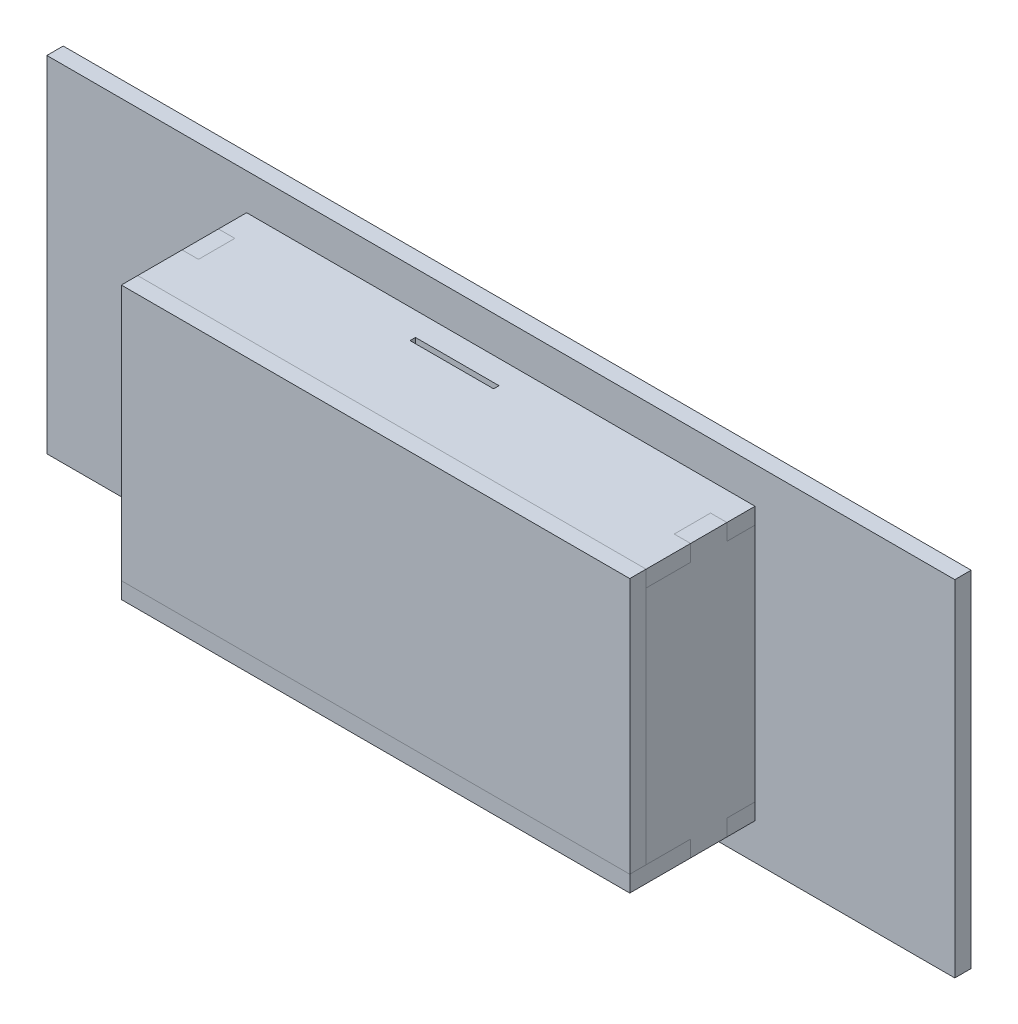
from build123d import *

# Parameters (mm, degrees)
ESQUISSE1_W             = 500
ESQUISSE1_H             = 190
ESQUISSE1_W_2           = 9
ESQUISSE1_H_2           = 37.5
ESQUISSE1_W_3           = 35
ESQUISSE1_H_3           = 9
BOSS_EXTRU_1_DEPTH      = 9
BOSS_EXTRU_2_START      = 9
ESQUISSE1_5_W           = 9
ESQUISSE1_5_H           = 9
ESQUISSE1_5_H_2         = 9.75
ESQUISSE1_5_H_3         = 37.5
BOSS_EXTRU_2_DEPTH      = 60
ESQUISSE1_6_W           = 9
ESQUISSE1_6_H           = 37.5
BOSS_EXTRU_3_DEPTH      = 9
ESQUISSE2_W             = 15.5
ESQUISSE2_H             = 9
ESQUISSE2_W_2           = 9
ENL_V_MAT_EXTRU_1_DEPTH = 408.291050724
BOSS_EXTRU_4_START      = 9
ESQUISSE1_7_W           = 35
ESQUISSE1_7_H           = 9
ESQUISSE1_7_W_2         = 8.5
ESQUISSE1_7_W_3         = 9
BOSS_EXTRU_4_DEPTH      = 60
ESQUISSE1_8_W           = 35
ESQUISSE1_8_H           = 9
BOSS_EXTRU_5_DEPTH      = 9
ESQUISSE3_W             = 9
ESQUISSE3_H             = 20
ENL_V_MAT_EXTRU_2_DEPTH = 311.098371489
BOSS_EXTRU_6_START      = 69
ESQUISSE1_9_W           = 9
ESQUISSE1_9_H           = 9
ESQUISSE1_9_W_2         = 8.5
ESQUISSE1_9_W_3         = 35
BOSS_EXTRU_6_DEPTH      = 9
BOSS_EXTRU_7_START      = 69
ESQUISSE1_10_W          = 262
ESQUISSE1_10_H          = 132
ESQUISSE1_10_W_2        = 9
ESQUISSE1_10_H_2        = 9.75
ESQUISSE1_10_H_3        = 37.5
ESQUISSE1_10_H_4        = 9
ESQUISSE1_10_W_3        = 8.5
ESQUISSE1_10_W_4        = 35
BOSS_EXTRU_7_DEPTH      = 9
ESQUISSE4_W             = 46
ESQUISSE4_H             = 3
ENL_V_MAT_EXTRU_3_DEPTH = 10


with BuildPart() as part:
    # Esquisse1 → Boss.-Extru.1 (new body)
    with BuildSketch(Plane.XY):
        Rectangle(ESQUISSE1_W, ESQUISSE1_H)
        with Locations((-135.5, 37.5)):
            Rectangle(ESQUISSE1_W_2, ESQUISSE1_H_2, mode=Mode.SUBTRACT)
        with Locations((-135.5, -37.5)):
            Rectangle(ESQUISSE1_W_2, ESQUISSE1_H_2, mode=Mode.SUBTRACT)
        with Locations((-105, -70.5)):
            Rectangle(ESQUISSE1_W_3, ESQUISSE1_H_3, mode=Mode.SUBTRACT)
        with Locations((-35, -70.5)):
            Rectangle(ESQUISSE1_W_3, ESQUISSE1_H_3, mode=Mode.SUBTRACT)
        with Locations((35, -70.5)):
            Rectangle(ESQUISSE1_W_3, ESQUISSE1_H_3, mode=Mode.SUBTRACT)
        with Locations((105, -70.5)):
            Rectangle(ESQUISSE1_W_3, ESQUISSE1_H_3, mode=Mode.SUBTRACT)
        with Locations((135.5, -37.5)):
            Rectangle(ESQUISSE1_W_2, ESQUISSE1_H_2, mode=Mode.SUBTRACT)
        with Locations((135.5, 37.5)):
            Rectangle(ESQUISSE1_W_2, ESQUISSE1_H_2, mode=Mode.SUBTRACT)
        with Locations((105, 70.5)):
            Rectangle(ESQUISSE1_W_3, ESQUISSE1_H_3, mode=Mode.SUBTRACT)
        with Locations((35, 70.5)):
            Rectangle(ESQUISSE1_W_3, ESQUISSE1_H_3, mode=Mode.SUBTRACT)
        with Locations((-35, 70.5)):
            Rectangle(ESQUISSE1_W_3, ESQUISSE1_H_3, mode=Mode.SUBTRACT)
        with Locations((-105, 70.5)):
            Rectangle(ESQUISSE1_W_3, ESQUISSE1_H_3, mode=Mode.SUBTRACT)
    extrude(amount=BOSS_EXTRU_1_DEPTH)


with BuildPart() as body_2:
    # Esquisse1_5 → Boss.-Extru.2 (new body)
    with BuildSketch(Plane.XY.offset(BOSS_EXTRU_2_START)):
        with Locations((-135.5, 70.5)):
            Rectangle(ESQUISSE1_5_W, ESQUISSE1_5_H)
        with Locations((-135.5, 61.125)):
            Rectangle(ESQUISSE1_5_W, ESQUISSE1_5_H_2)
        with Locations((-135.5, 37.5)):
            Rectangle(ESQUISSE1_5_W, ESQUISSE1_5_H_3)
        with Locations((-135.5, 0)):
            Rectangle(ESQUISSE1_5_W, ESQUISSE1_5_H_3)
        with Locations((-135.5, -37.5)):
            Rectangle(ESQUISSE1_5_W, ESQUISSE1_5_H_3)
        with Locations((-135.5, -61.125)):
            Rectangle(ESQUISSE1_5_W, ESQUISSE1_5_H_2)
        with Locations((-135.5, -70.5)):
            Rectangle(ESQUISSE1_5_W, ESQUISSE1_5_H)
    extrude(amount=BOSS_EXTRU_2_DEPTH)

    # Esquisse1_6 → Boss.-Extru.3 (add)
    with BuildSketch(Plane.XY):
        with Locations((-135.5, 37.5)):
            Rectangle(ESQUISSE1_6_W, ESQUISSE1_6_H)
        with Locations((-135.5, -37.5)):
            Rectangle(ESQUISSE1_6_W, ESQUISSE1_6_H)
    extrude(amount=BOSS_EXTRU_3_DEPTH)

    # Esquisse2 → Enlèv. mat.-Extru.1 (cut, through all)
    with BuildSketch(Plane.ZY.offset(140)):
        with Locations((16.75, 70.5)):
            Rectangle(ESQUISSE2_W, ESQUISSE2_H)
        with Locations((4.5, 70.5)):
            Rectangle(ESQUISSE2_W_2, ESQUISSE2_H)
        Polygon((44.5, 75), (44.5, 66), (60, 66), (69, 66), (69, 75), align=None)
        Polygon((69, -66), (60, -66), (44.5, -66), (44.5, -75), (69, -75), align=None)
        with Locations((16.75, -70.5)):
            Rectangle(ESQUISSE2_W, ESQUISSE2_H)
        with Locations((4.5, -70.5)):
            Rectangle(ESQUISSE2_W_2, ESQUISSE2_H)
    extrude(amount=-ENL_V_MAT_EXTRU_1_DEPTH, mode=Mode.SUBTRACT)


with BuildPart() as body_3:
    # Symétrie1: mirrored copy
    add(body_2.part.mirror(Plane(origin=(0, 0, 0), x_dir=(0, 0, 1), z_dir=(1, 0, 0))))


with BuildPart() as body_4:
    # Esquisse1_7 → Boss.-Extru.4 (new body)
    with BuildSketch(Plane.XY.offset(BOSS_EXTRU_4_START)):
        with Locations((-70, -70.5)):
            Rectangle(ESQUISSE1_7_W, ESQUISSE1_7_H)
        with Locations((-35, -70.5)):
            Rectangle(ESQUISSE1_7_W, ESQUISSE1_7_H)
        with Locations((0, -70.5)):
            Rectangle(ESQUISSE1_7_W, ESQUISSE1_7_H)
        with Locations((35, -70.5)):
            Rectangle(ESQUISSE1_7_W, ESQUISSE1_7_H)
        with Locations((70, -70.5)):
            Rectangle(ESQUISSE1_7_W, ESQUISSE1_7_H)
        with Locations((105, -70.5)):
            Rectangle(ESQUISSE1_7_W, ESQUISSE1_7_H)
        with Locations((126.75, -70.5)):
            Rectangle(ESQUISSE1_7_W_2, ESQUISSE1_7_H)
        with Locations((135.5, -70.5)):
            Rectangle(ESQUISSE1_7_W_3, ESQUISSE1_7_H)
        with Locations((-105, -70.5)):
            Rectangle(ESQUISSE1_7_W, ESQUISSE1_7_H)
        with Locations((-126.75, -70.5)):
            Rectangle(ESQUISSE1_7_W_2, ESQUISSE1_7_H)
        with Locations((-135.5, -70.5)):
            Rectangle(ESQUISSE1_7_W_3, ESQUISSE1_7_H)
    extrude(amount=BOSS_EXTRU_4_DEPTH)

    # Esquisse1_8 → Boss.-Extru.5 (add)
    with BuildSketch(Plane.XY):
        with Locations((-105, -70.5)):
            Rectangle(ESQUISSE1_8_W, ESQUISSE1_8_H)
        with Locations((-35, -70.5)):
            Rectangle(ESQUISSE1_8_W, ESQUISSE1_8_H)
        with Locations((35, -70.5)):
            Rectangle(ESQUISSE1_8_W, ESQUISSE1_8_H)
        with Locations((105, -70.5)):
            Rectangle(ESQUISSE1_8_W, ESQUISSE1_8_H)
    extrude(amount=BOSS_EXTRU_5_DEPTH)

    # Esquisse3 → Enlèv. mat.-Extru.2 (cut, through all)
    with BuildSketch(Plane.XZ.offset(75)):
        with Locations((-135.5, 34.5)):
            Rectangle(ESQUISSE3_W, ESQUISSE3_H)
        with Locations((135.5, 34.5)):
            Rectangle(ESQUISSE3_W, ESQUISSE3_H)
    extrude(amount=-ENL_V_MAT_EXTRU_2_DEPTH, mode=Mode.SUBTRACT)


with BuildPart() as body_5:
    # Symétrie2: mirrored copy
    add(body_4.part.mirror(Plane.ZX))

    # Esquisse4 → Enlèv. mat.-Extru.3 (cut)
    with BuildSketch(Plane(origin=(0, 75, 0), x_dir=(1, 0, 0), z_dir=(0, 1, 0))):
        with Locations((-11, -23.5)):
            Rectangle(ESQUISSE4_W, ESQUISSE4_H)
    extrude(amount=-ENL_V_MAT_EXTRU_3_DEPTH, mode=Mode.SUBTRACT)


with BuildPart() as body_4_1:
    add(body_4.part)

    # Esquisse1_9 → Boss.-Extru.6 (add)
    with BuildSketch(Plane.XY.offset(BOSS_EXTRU_6_START)):
        with Locations((135.5, -70.5)):
            Rectangle(ESQUISSE1_9_W, ESQUISSE1_9_H)
        with Locations((126.75, -70.5)):
            Rectangle(ESQUISSE1_9_W_2, ESQUISSE1_9_H)
        with Locations((105, -70.5)):
            Rectangle(ESQUISSE1_9_W_3, ESQUISSE1_9_H)
        with Locations((70, -70.5)):
            Rectangle(ESQUISSE1_9_W_3, ESQUISSE1_9_H)
        with Locations((35, -70.5)):
            Rectangle(ESQUISSE1_9_W_3, ESQUISSE1_9_H)
        with Locations((0, -70.5)):
            Rectangle(ESQUISSE1_9_W_3, ESQUISSE1_9_H)
        with Locations((-35, -70.5)):
            Rectangle(ESQUISSE1_9_W_3, ESQUISSE1_9_H)
        with Locations((-70, -70.5)):
            Rectangle(ESQUISSE1_9_W_3, ESQUISSE1_9_H)
        with Locations((-105, -70.5)):
            Rectangle(ESQUISSE1_9_W_3, ESQUISSE1_9_H)
        with Locations((-126.75, -70.5)):
            Rectangle(ESQUISSE1_9_W_2, ESQUISSE1_9_H)
        with Locations((-135.5, -70.5)):
            Rectangle(ESQUISSE1_9_W, ESQUISSE1_9_H)
    extrude(amount=BOSS_EXTRU_6_DEPTH)


with BuildPart() as body_6:
    # Esquisse1_10 → Boss.-Extru.7 (new body)
    with BuildSketch(Plane.XY.offset(BOSS_EXTRU_7_START)):
        Rectangle(ESQUISSE1_10_W, ESQUISSE1_10_H)
        with Locations((135.5, -61.125)):
            Rectangle(ESQUISSE1_10_W_2, ESQUISSE1_10_H_2)
        with Locations((135.5, -37.5)):
            Rectangle(ESQUISSE1_10_W_2, ESQUISSE1_10_H_3)
        with Locations((135.5, 0)):
            Rectangle(ESQUISSE1_10_W_2, ESQUISSE1_10_H_3)
        with Locations((135.5, 37.5)):
            Rectangle(ESQUISSE1_10_W_2, ESQUISSE1_10_H_3)
        with Locations((135.5, 70.5)):
            Rectangle(ESQUISSE1_10_W_2, ESQUISSE1_10_H_4)
        with Locations((126.75, 70.5)):
            Rectangle(ESQUISSE1_10_W_3, ESQUISSE1_10_H_4)
        with Locations((105, 70.5)):
            Rectangle(ESQUISSE1_10_W_4, ESQUISSE1_10_H_4)
        with Locations((70, 70.5)):
            Rectangle(ESQUISSE1_10_W_4, ESQUISSE1_10_H_4)
        with Locations((35, 70.5)):
            Rectangle(ESQUISSE1_10_W_4, ESQUISSE1_10_H_4)
        with Locations((0, 70.5)):
            Rectangle(ESQUISSE1_10_W_4, ESQUISSE1_10_H_4)
        with Locations((-35, 70.5)):
            Rectangle(ESQUISSE1_10_W_4, ESQUISSE1_10_H_4)
        with Locations((-70, 70.5)):
            Rectangle(ESQUISSE1_10_W_4, ESQUISSE1_10_H_4)
        with Locations((-105, 70.5)):
            Rectangle(ESQUISSE1_10_W_4, ESQUISSE1_10_H_4)
        with Locations((-135.5, 70.5)):
            Rectangle(ESQUISSE1_10_W_2, ESQUISSE1_10_H_4)
        with Locations((-135.5, 61.125)):
            Rectangle(ESQUISSE1_10_W_2, ESQUISSE1_10_H_2)
        with Locations((-126.75, 70.5)):
            Rectangle(ESQUISSE1_10_W_3, ESQUISSE1_10_H_4)
        with Locations((-135.5, 37.5)):
            Rectangle(ESQUISSE1_10_W_2, ESQUISSE1_10_H_3)
        with Locations((-135.5, 0)):
            Rectangle(ESQUISSE1_10_W_2, ESQUISSE1_10_H_3)
        with Locations((-135.5, -37.5)):
            Rectangle(ESQUISSE1_10_W_2, ESQUISSE1_10_H_3)
        with Locations((-135.5, -61.125)):
            Rectangle(ESQUISSE1_10_W_2, ESQUISSE1_10_H_2)
        with Locations((135.5, 61.125)):
            Rectangle(ESQUISSE1_10_W_2, ESQUISSE1_10_H_2)
    extrude(amount=BOSS_EXTRU_7_DEPTH)


solid = Compound([part.part, body_2.part, body_3.part, body_5.part, body_4_1.part, body_6.part])
